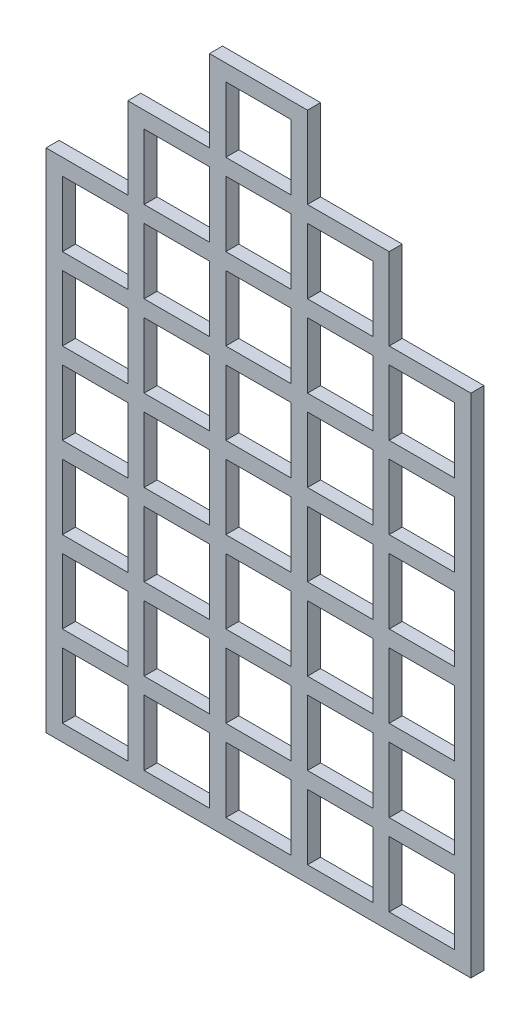
from build123d import *

# Parameters (mm, degrees)
SKETCH_1_W             = 12.5
SKETCH_1_H             = 0.5
EXTRUDE_1_DEPTH        = 0.4
PATTERN_LINEAR_1_COUNT = 7
PATTERN_LINEAR_1_PITCH = 2.5
EXTRUDE_3_DEPTH        = 0.4
PATTERN_LINEAR_2_COUNT = 7
PATTERN_LINEAR_2_PITCH = 2.5
SKETCH_4_W             = 0.5
SKETCH_4_H             = 2.5
EXTRUDE_4_DEPTH        = 0.4
SKETCH_6_W             = 0.5
SKETCH_6_H             = 2.5
EXTRUDE_6_DEPTH        = 0.4
SKETCH_7_W             = 10.5
SKETCH_7_H             = 0.5
SKETCH_7_W_2           = 5.5
EXTRUDE_7_DEPTH        = 0.4
CUT_EXTRUDE_2_DEPTH    = 10


with BuildPart() as part:
    # Sketch 1 → Extrude 1 (new body)
    with BuildSketch(Plane.XY):
        with Locations((6.25, 0.25)):
            Rectangle(SKETCH_1_W, SKETCH_1_H)
    extrude(amount=EXTRUDE_1_DEPTH)


with BuildPart() as pattern_linear_1_1:
    # Pattern Linear 1: pattern copy
    add(part.part.moved(Location(Vector(0, 1, 0) * (1 * PATTERN_LINEAR_1_PITCH))))


with BuildPart() as pattern_linear_1_2:
    # Pattern Linear 1: pattern copy
    add(part.part.moved(Location(Vector(0, 1, 0) * (2 * PATTERN_LINEAR_1_PITCH))))


with BuildPart() as pattern_linear_1_3:
    # Pattern Linear 1: pattern copy
    add(part.part.moved(Location(Vector(0, 1, 0) * (3 * PATTERN_LINEAR_1_PITCH))))


with BuildPart() as pattern_linear_1_4:
    # Pattern Linear 1: pattern copy
    add(part.part.moved(Location(Vector(0, 1, 0) * (4 * PATTERN_LINEAR_1_PITCH))))


with BuildPart() as pattern_linear_1_5:
    # Pattern Linear 1: pattern copy
    add(part.part.moved(Location(Vector(0, 1, 0) * (5 * PATTERN_LINEAR_1_PITCH))))


with BuildPart() as pattern_linear_1_6:
    # Pattern Linear 1: pattern copy
    add(part.part.moved(Location(Vector(0, 1, 0) * (6 * PATTERN_LINEAR_1_PITCH))))

    # Sketch 4 → Extrude 4 (add)
    with BuildSketch(Plane.XY.offset(0.4)):
        with Locations((4.75, 16.75)):
            Rectangle(SKETCH_4_W, SKETCH_4_H)
        with Locations((2.25, 16.75)):
            Rectangle(SKETCH_4_W, SKETCH_4_H)
        with Locations((7.25, 16.75)):
            Rectangle(SKETCH_4_W, SKETCH_4_H)
        with Locations((9.75, 16.75)):
            Rectangle(SKETCH_4_W, SKETCH_4_H)
    extrude(amount=-EXTRUDE_4_DEPTH)

    # Sketch 6 → Extrude 6 (add)
    with BuildSketch(Plane.XY.offset(0.4)):
        with Locations((4.75, 19.25)):
            Rectangle(SKETCH_6_W, SKETCH_6_H)
        with Locations((9.75, 19.25)):
            Rectangle(SKETCH_6_W, SKETCH_6_H)
        with Locations((7.25, 19.25)):
            Rectangle(SKETCH_6_W, SKETCH_6_H)
    extrude(amount=-EXTRUDE_6_DEPTH)

    # Sketch 7 → Extrude 7 (add)
    with BuildSketch(Plane.XY.offset(0.4)):
        with Locations((7.25, 17.75)):
            Rectangle(SKETCH_7_W, SKETCH_7_H)
        with Locations((7.25, 20.25)):
            Rectangle(SKETCH_7_W_2, SKETCH_7_H)
    extrude(amount=-EXTRUDE_7_DEPTH)

    # Sketch 9 → Cut-Extrude 2 (cut)
    with BuildSketch(Plane.XY.offset(0.4)):
        Polygon((9.5, 18), (10, 18), (10, 15.5), (12.5, 15.5), (12.5, 20), (10, 20), (10, 20.5), (7.5, 20.5), (7.5, 20), (9.5, 20), align=None)
    extrude(amount=-CUT_EXTRUDE_2_DEPTH, mode=Mode.SUBTRACT)


with BuildPart() as part_1:
    add(part.part)

    add(pattern_linear_1_1.part)  # Extrude 3 merges Pattern Linear 1_1

    add(pattern_linear_1_2.part)  # Extrude 3 merges Pattern Linear 1_2

    add(pattern_linear_1_3.part)  # Extrude 3 merges Pattern Linear 1_3
    # Sketch 3 → Extrude 3 (add)
    with BuildSketch(Plane.XY.offset(0.4)):
        Polygon((0, 15.5), (0, 8), (0, 0), (-0.5, 0), (-0.5, 10.98507125), (-0.5, 15.5), align=None)
    extrude_3 = extrude(amount=-EXTRUDE_3_DEPTH)

    # Pattern Linear 2: Extrude 3 ×7, 1 skipped
    with Locations(*[(i * PATTERN_LINEAR_2_PITCH, 0, 0) for i in range(1, PATTERN_LINEAR_2_COUNT) if i not in (6,)]):
        add(extrude_3)

    # Combine 1: union Pattern Linear 1_5, Pattern Linear 1_4
    add(pattern_linear_1_5.part)
    add(pattern_linear_1_4.part)

    # Combine 2: union Pattern Linear 1_6
    add(pattern_linear_1_6.part)


solid = part_1.part
